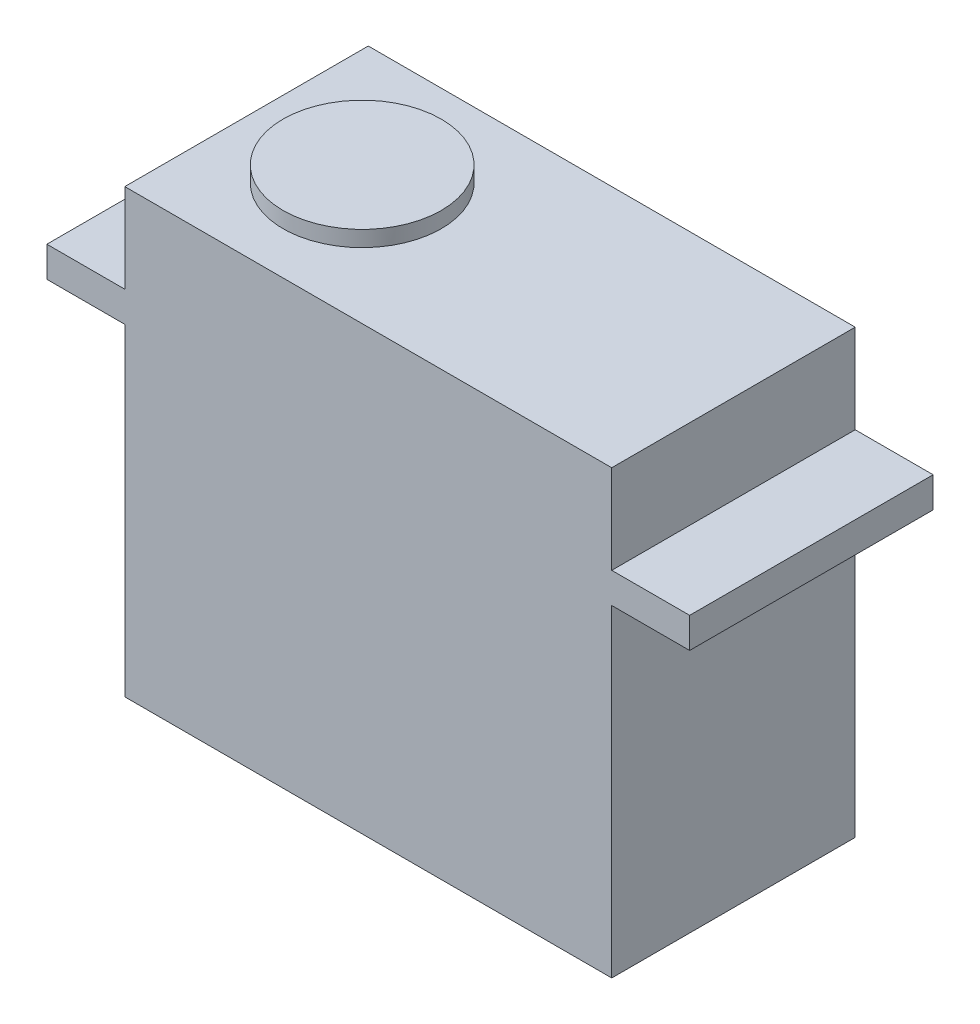
from build123d import *

# Parameters (mm, degrees)
SKETCH1_W           = 40
SKETCH1_H           = 20
BOSS_EXTRUDE1_DEPTH = 26.5
SKETCH2_W           = 52.8
SKETCH2_H           = 20
BOSS_EXTRUDE2_DEPTH = 2.5
SKETCH3_W           = 40
SKETCH3_H           = 20
BOSS_EXTRUDE3_DEPTH = 7.3
SKETCH4_R           = 6.5
BOSS_EXTRUDE4_DEPTH = 1.3


with BuildPart() as part:
    # Sketch1 → Boss-Extrude1 (new body)
    with BuildSketch(Plane(origin=(0, 0, 0), x_dir=(1, 0, 0), z_dir=(0, 1, 0))):
        Rectangle(SKETCH1_W, SKETCH1_H)
    extrude(amount=BOSS_EXTRUDE1_DEPTH)

    # Sketch2 → Boss-Extrude2 (add)
    with BuildSketch(Plane(origin=(0, 26.5, 0), x_dir=(1, 0, 0), z_dir=(0, 1, 0))):
        Rectangle(SKETCH2_W, SKETCH2_H)
    extrude(amount=BOSS_EXTRUDE2_DEPTH)

    # Sketch3 → Boss-Extrude3 (add)
    with BuildSketch(Plane(origin=(0, 29, 0), x_dir=(1, 0, 0), z_dir=(0, 1, 0))):
        Rectangle(SKETCH3_W, SKETCH3_H)
    extrude(amount=BOSS_EXTRUDE3_DEPTH)

    # Sketch4 → Boss-Extrude4 (add)
    with BuildSketch(Plane(origin=(0, 36.3, 0), x_dir=(1, 0, 0), z_dir=(0, 1, 0))):
        with Locations((-10.5, 0)):
            Circle(SKETCH4_R)
    extrude(amount=BOSS_EXTRUDE4_DEPTH)


solid = part.part
